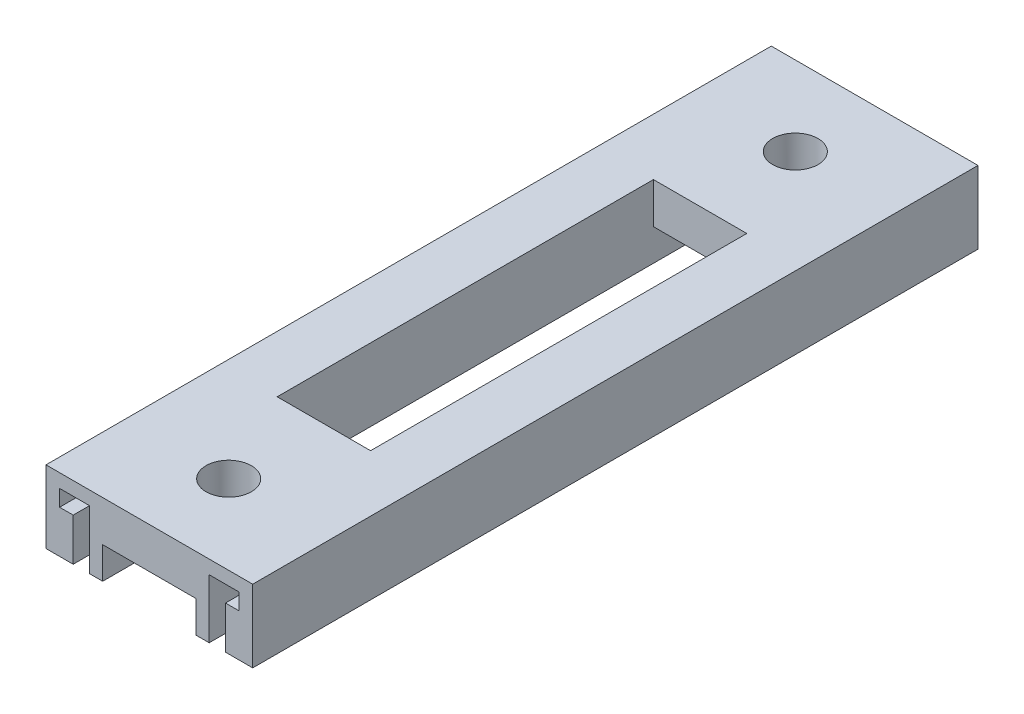
from build123d import *

# Parameters (mm, degrees)
BOSS_EXTRUDE1_DEPTH   = 160
BOSS_EXTRUDE1_2_DEPTH = 160
BOSS_EXTRUDE2_START   = 16
SKETCH3_W             = 20.6
SKETCH3_H             = 160
BOSS_EXTRUDE2_DEPTH   = 9
CUT_EXTRUDE1_START    = 16
SKETCH4_R             = 5
CUT_EXTRUDE1_DEPTH    = 9
CUT_EXTRUDE2_START    = 16
SKETCH5_W             = 20.6
SKETCH5_H             = 83
CUT_EXTRUDE2_DEPTH    = 9


with BuildPart() as part:
    # Sketch2 → Boss-Extrude1 (new body)
    with BuildSketch(Plane.XY):
        Polygon((0, 0), (0, 9.4), (-3, 9.4), (-3, 13), (3.6, 13), (3.6, 0), (6.5, 0), (6.5, 16), (-6, 16), (-6, 0), align=None)
    extrude(amount=BOSS_EXTRUDE1_DEPTH)



with BuildPart() as body_2:
    # Sketch2 → Boss-Extrude1 2 (new body)
    with BuildSketch(Plane.XY):
        Polygon((39.6, 0), (33.6, 0), (33.6, 9.4), (36.6, 9.4), (36.6, 13), (30, 13), (30, 0), (27.1, 0), (27.1, 16), (39.6, 16), align=None)
    extrude(amount=BOSS_EXTRUDE1_2_DEPTH)


with BuildPart() as part_1:
    add(part.part)

    add(body_2.part)  # Boss-Extrude2 merges body 2
    # Sketch3 → Boss-Extrude2 (add)
    with BuildSketch(Plane(origin=(0, 0, 0), x_dir=(1, 0, 0), z_dir=(0, 1, 0)).offset(BOSS_EXTRUDE2_START)):
        with Locations((16.8, -80)):
            Rectangle(SKETCH3_W, SKETCH3_H)
    extrude(amount=-BOSS_EXTRUDE2_DEPTH)

    # Sketch4 → Cut-Extrude1 (cut)
    with BuildSketch(Plane(origin=(0, 0, 0), x_dir=(1, 0, 0), z_dir=(0, 1, 0)).offset(CUT_EXTRUDE1_START)):
        with Locations((16.8, -17.5)):
            Circle(SKETCH4_R)
        with Locations((16.8, -142.5)):
            Circle(SKETCH4_R)
    extrude(amount=-CUT_EXTRUDE1_DEPTH, mode=Mode.SUBTRACT)

    # Sketch5 → Cut-Extrude2 (cut)
    with BuildSketch(Plane(origin=(0, 0, 0), x_dir=(1, 0, 0), z_dir=(0, 1, 0)).offset(CUT_EXTRUDE2_START)):
        with Locations((16.8, -80)):
            Rectangle(SKETCH5_W, SKETCH5_H)
    extrude(amount=-CUT_EXTRUDE2_DEPTH, mode=Mode.SUBTRACT)


solid = part_1.part
